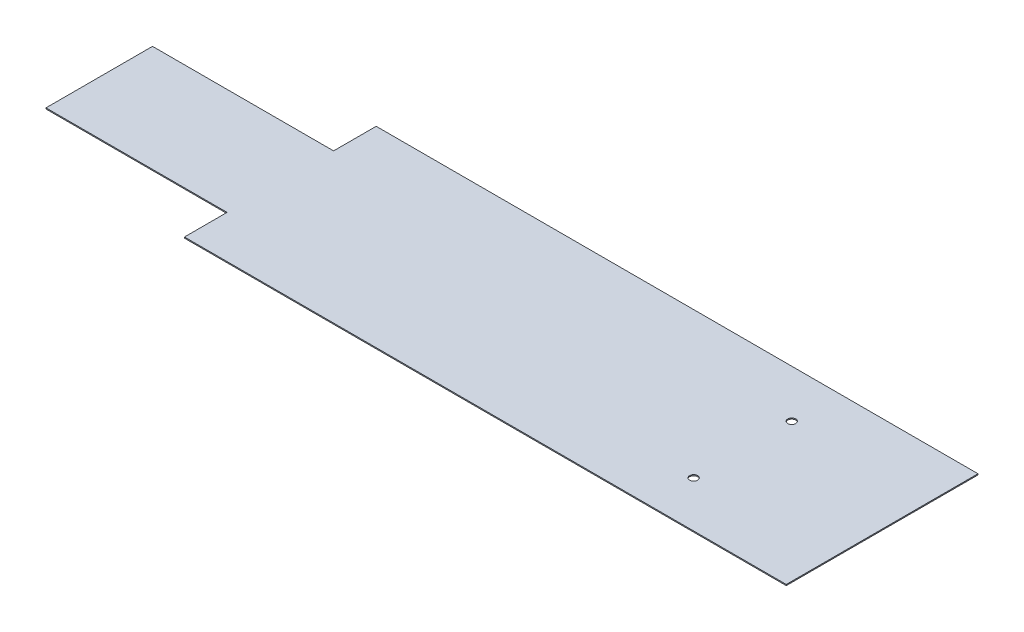
from build123d import *

# Parameters (mm, degrees)
BOSS_EXTRUDE1_DEPTH = 2
SKETCH2_R           = 7.5
CUT_EXTRUDE1_DEPTH  = 2


with BuildPart() as part:
    # Sketch1 → Boss-Extrude1 (new body)
    with BuildSketch(Plane(origin=(0, 0, 0), x_dir=(1, 0, 0), z_dir=(0, 1, 0))):
        Polygon((-752.940260226, -63.215240642), (-752.940260226, -143.215240642), (377.059739774, -143.215240642), (377.059739774, 216.784759358), (-752.940260226, 216.784759358), (-752.940260226, 136.784759358), (-1092.940260226, 136.784759358), (-1092.940260226, -63.215240642), align=None)
    extrude(amount=BOSS_EXTRUDE1_DEPTH)

    # Sketch2 → Cut-Extrude1 (cut)
    with BuildSketch(Plane(origin=(0, 2, 0), x_dir=(1, 0, 0), z_dir=(0, 1, 0))):
        with Locations((116.805980262, 127.350148458)):
            Circle(SKETCH2_R)
        with Locations((116.805980262, -56.884027166)):
            Circle(SKETCH2_R)
    extrude(amount=-CUT_EXTRUDE1_DEPTH, mode=Mode.SUBTRACT)


solid = part.part
